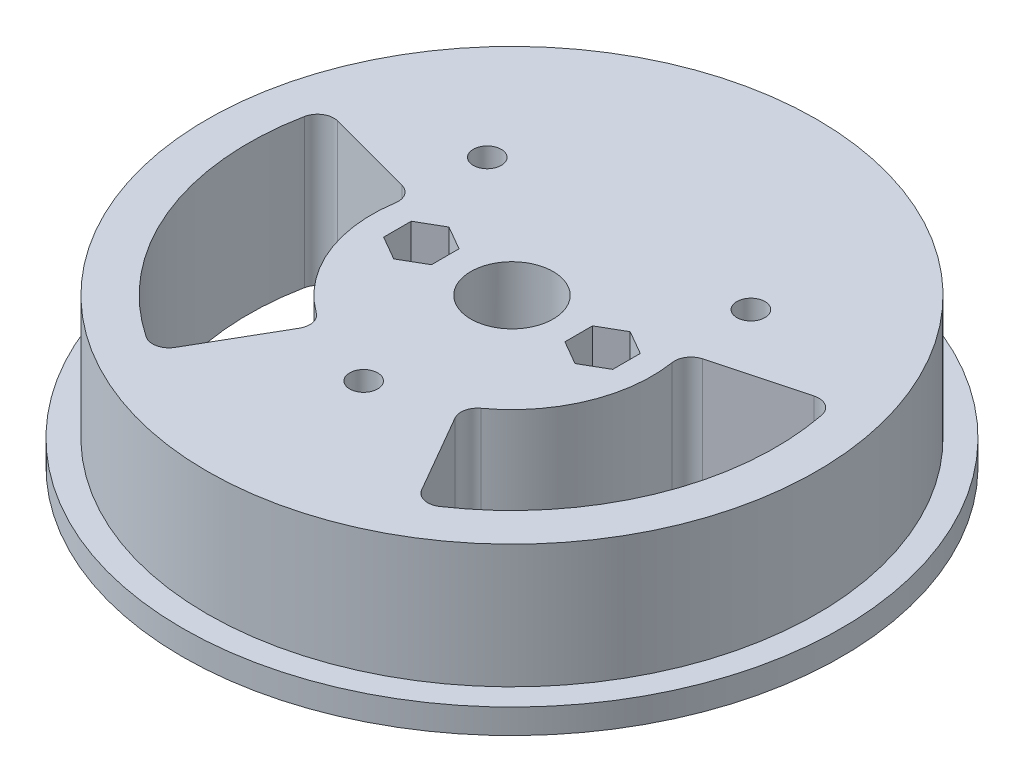
from build123d import *

# Parameters (mm, degrees)
CORTAR_EXTRUIR1_DEPTH      = 13
CROQUIS3_R                 = 1.7
CORTAR_EXTRUIR2_DEPTH      = 17
CORTAR_EXTRUIR3_DEPTH      = 1.5
CORTAR_EXTRUIR3_DEPTH_BACK = 1.5
CROQUIS5_R                 = 5
CORTAR_EXTRUIR4_DEPTH      = 18
CROQUIS6_R                 = 8.2
CORTAR_EXTRUIR5_DEPTH      = 9
CROQUIS7_W                 = 30.6
CROQUIS7_H                 = 7
CORTAR_EXTRUIR6_DEPTH      = 4
CROQUIS8_R                 = 1.7
CORTAR_EXTRUIR7_DEPTH      = 14
CORTAR_EXTRUIR8_DEPTH      = 11
CORTAR_EXTRUIR9_DEPTH      = 18
CROQUIS11_R                = 1.7
CORTAR_EXTRUIR10_DEPTH     = 18
CROQUIS12_R                = 2.95
CORTAR_EXTRUIR11_DEPTH     = 3


with BuildPart() as part:
    # Croquis1 → Revolución1 (revolve)
    with BuildSketch(Plane.XY):
        Polygon((0, 0), (40, 0), (40, 3), (37, 3), (37, 18), (0, 18), align=None)
    revolve(axis=Axis((0, 18, 0), (0, -1, 0)))

    # Croquis2 → Cortar-Extruir1 (cut)
    with BuildSketch(Plane.XZ):
        Polygon((-11.5, -19.5), (11.5, -19.5), (11.5, -23), (5, -29.5), (5, -54.5), (2.5, -54.5), (2.5, -29.5), (9, -23), (-9, -23), (-2.5, -29.5), (-2.5, -54.5), (-5, -54.5), (-5, -29.5), (-11.5, -23), align=None)
    extrude(amount=-CORTAR_EXTRUIR1_DEPTH, mode=Mode.SUBTRACT)

    # Croquis3 → Cortar-Extruir2 (cut)
    with BuildSketch(Plane.XY.offset(-40)):
        with Locations((0, 6.5)):
            Circle(CROQUIS3_R)
    extrude(amount=CORTAR_EXTRUIR2_DEPTH, mode=Mode.SUBTRACT)

    # Croquis4 → Cortar-Extruir3 (cut, two sides)
    with BuildSketch(Plane.XY.offset(-25.85)) as cortar_extruir3_sk:
        Polygon((0, 9.85), (-2.901185103, 8.175), (-2.901185103, 4.825), (-2.901185103, -1.825), (2.901185103, -1.825), (2.901185103, 4.825), (2.901185103, 8.175), align=None)
    extrude(amount=CORTAR_EXTRUIR3_DEPTH, mode=Mode.SUBTRACT)
    extrude(cortar_extruir3_sk.sketch, amount=-CORTAR_EXTRUIR3_DEPTH_BACK, mode=Mode.SUBTRACT)

    # Croquis5 → Cortar-Extruir4 (cut)
    with BuildSketch(Plane(origin=(0, 18, 0), x_dir=(1, 0, 0), z_dir=(0, 1, 0))):
        Circle(CROQUIS5_R)
    extrude(amount=-CORTAR_EXTRUIR4_DEPTH, mode=Mode.SUBTRACT)

    # Croquis6 → Cortar-Extruir5 (cut)
    with BuildSketch(Plane.XZ):
        Circle(CROQUIS6_R)
    extrude(amount=-CORTAR_EXTRUIR5_DEPTH, mode=Mode.SUBTRACT)

    # Croquis7 → Cortar-Extruir6 (cut)
    with BuildSketch(Plane.XZ):
        Rectangle(CROQUIS7_W, CROQUIS7_H)
    extrude(amount=-CORTAR_EXTRUIR6_DEPTH, mode=Mode.SUBTRACT)

    # Croquis8 → Cortar-Extruir7 (cut)
    with BuildSketch(Plane.XZ.offset(-4)):
        with Locations((-11, 0)):
            Circle(CROQUIS8_R)
        with Locations((11, 0)):
            Circle(CROQUIS8_R)
    extrude(amount=-CORTAR_EXTRUIR7_DEPTH, mode=Mode.SUBTRACT)

    # Croquis9 → Cortar-Extruir8 (cut)
    with BuildSketch(Plane(origin=(0, 18, 0), x_dir=(1, 0, 0), z_dir=(0, 1, 0))):
        Polygon((-11, 3.35), (-13.901185103, 1.675), (-13.901185103, -1.675), (-11, -3.35), (-8.098814897, -1.675), (-8.098814897, 1.675), align=None)
        Polygon((11, 3.35), (8.098814897, 1.675), (8.098814897, -1.675), (11, -3.35), (13.901185103, -1.675), (13.901185103, 1.675), align=None)
    extrude(amount=-CORTAR_EXTRUIR8_DEPTH, mode=Mode.SUBTRACT)

    # Croquis10 → Cortar-Extruir9 (cut)
    with BuildSketch(Plane.XZ):
        with BuildLine():
            Line((9.447221814, 16.363068172), (14.966629547, 25.922962794))
            ThreePointArc((14.966629547, 25.922962794), (16.245761141, 26.871003909), (17.811925712, 26.584493647))
            ThreePointArc((17.811925712, 26.584493647), (29.56414504, 12.245869836), (31.393009189, -6.203142275))
            ThreePointArc((31.393009189, -6.203142275), (30.48815695, -7.513181213), (28.913308024, -7.747297536))
            Line((28.913308024, -7.747297536), (18.250631073, -4.890241857))
            ThreePointArc((18.250631073, -4.890241857), (17.091330505, -4.048287785), (16.792661883, -2.64698071))
            ThreePointArc((16.792661883, -2.64698071), (15.705952053, 6.50561835), (10.002507082, 13.745903101))
            ThreePointArc((10.002507082, 13.745903101), (9.222823954, 14.947967445), (9.447221814, 16.363068172))
        make_face()
    cortar_extruir9 = extrude(amount=-CORTAR_EXTRUIR9_DEPTH, mode=Mode.SUBTRACT)

    # Simetría1: Cortar-Extruir9 across plane
    add(cortar_extruir9.mirror(Plane(origin=(0, 0, 0), x_dir=(0, 0, 1), z_dir=(1, 0, 0))), mode=Mode.SUBTRACT)

    # Croquis11 → Cortar-Extruir10 (cut)
    with BuildSketch(Plane.XZ):
        with Locations((-16, -13)):
            Circle(CROQUIS11_R)
        with Locations((16, -13)):
            Circle(CROQUIS11_R)
        with Locations((0, 18)):
            Circle(CROQUIS11_R)
    extrude(amount=-CORTAR_EXTRUIR10_DEPTH, mode=Mode.SUBTRACT)

    # Croquis12 → Cortar-Extruir11 (cut)
    with BuildSketch(Plane.XZ):
        with Locations((-16, -13)):
            Circle(CROQUIS12_R)
        with Locations((16, -13)):
            Circle(CROQUIS12_R)
        with Locations((0, 18)):
            Circle(CROQUIS12_R)
    extrude(amount=-CORTAR_EXTRUIR11_DEPTH, mode=Mode.SUBTRACT)


solid = part.part
